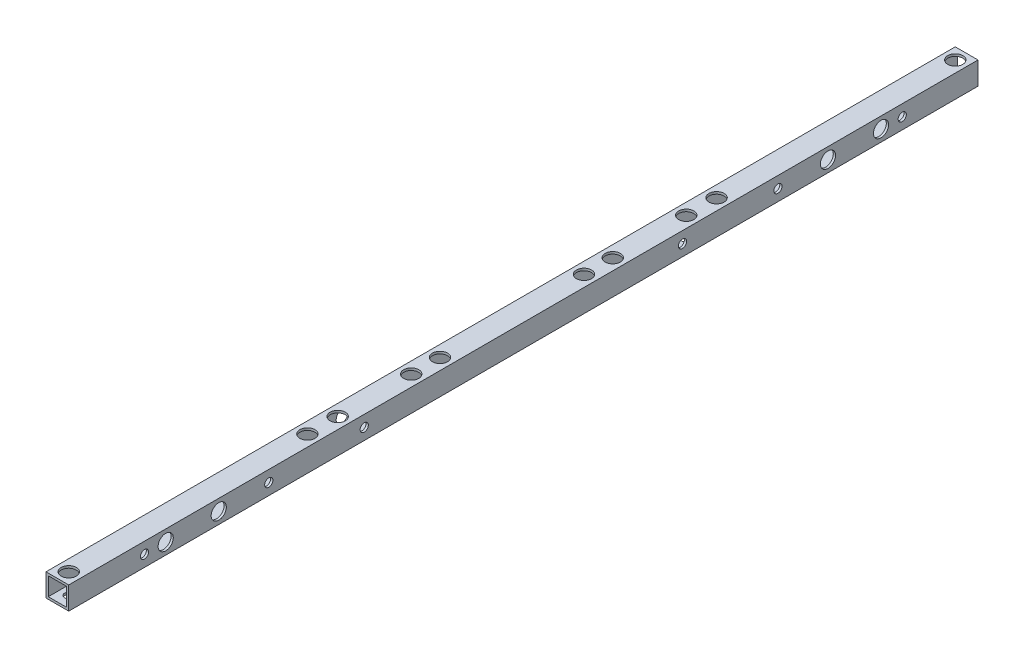
from build123d import *

# Parameters (mm, degrees)
SKETCH_1_W          = 15
SKETCH_1_H          = 15
SKETCH_1_W_2        = 12
SKETCH_1_H_2        = 12
EXTRUDE_1_DEPTH     = 600
SKETCH_3_R          = 2.7
CUT_EXTRUDE_2_DEPTH = 25
SKETCH_4_R          = 2.7
CUT_EXTRUDE_3_DEPTH = 20
SKETCH_6_R          = 2.7
CUT_EXTRUDE_5_DEPTH = 30
SKETCH_7_R          = 5
CUT_EXTRUDE_6_DEPTH = 10
SKETCH_8_R          = 5
CUT_EXTRUDE_7_DEPTH = 10
SKETCH_9_R          = 5
CUT_EXTRUDE_8_DEPTH = 10


with BuildPart() as part:
    # ｽｹｯﾁ1 → ﾎﾞｽ - 押し出し1 (new body)
    with BuildSketch(Plane.XY):
        Rectangle(SKETCH_1_W, SKETCH_1_H)
        Rectangle(SKETCH_1_W_2, SKETCH_1_H_2, mode=Mode.SUBTRACT)
    extrude(amount=EXTRUDE_1_DEPTH)

    # ｽｹｯﾁ3 → ｶｯﾄ - 押し出し2 (cut)
    with BuildSketch(Plane(origin=(0, 7.5, 0), x_dir=(1, 0, 0), z_dir=(0, 1, 0))):
        with Locations((0, -7.5)):
            Circle(SKETCH_3_R)
        with Locations((0, -592.5)):
            Circle(SKETCH_3_R)
        with Locations((0, -233.5)):
            Circle(SKETCH_3_R)
        with Locations((0, -366.5)):
            Circle(SKETCH_3_R)
    extrude(amount=-CUT_EXTRUDE_2_DEPTH, mode=Mode.SUBTRACT)

    # ｽｹｯﾁ4 → ｶｯﾄ - 押し出し3 (cut)
    with BuildSketch(Plane(origin=(7.5, 0, 0), x_dir=(0, 0, -1), z_dir=(1, 0, 0))):
        with Locations((-536, 0)):
            Circle(SKETCH_4_R)
        with Locations((-501, 0)):
            Circle(SKETCH_4_R)
        with Locations((-99, 0)):
            Circle(SKETCH_4_R)
        with Locations((-64, 0)):
            Circle(SKETCH_4_R)
        with Locations((-468, 0)):
            Circle(SKETCH_4_R)
        with Locations((-550, 0)):
            Circle(SKETCH_4_R)
        with Locations((-405, 0)):
            Circle(SKETCH_4_R)
        with Locations((-195, 0)):
            Circle(SKETCH_4_R)
        with Locations((-50, 0)):
            Circle(SKETCH_4_R)
        with Locations((-132, 0)):
            Circle(SKETCH_4_R)
    extrude(amount=-CUT_EXTRUDE_3_DEPTH, mode=Mode.SUBTRACT)

    # ｽｹｯﾁ6 → ｶｯﾄ - 押し出し5 (cut)
    with BuildSketch(Plane(origin=(0, 7.5, 0), x_dir=(1, 0, 0), z_dir=(0, 1, 0))):
        with Locations((0, -435)):
            Circle(SKETCH_6_R)
        with Locations((0, -415)):
            Circle(SKETCH_6_R)
        with Locations((0, -165)):
            Circle(SKETCH_6_R)
        with Locations((0, -185)):
            Circle(SKETCH_6_R)
        with Locations((0, -347.5)):
            Circle(SKETCH_6_R)
        with Locations((0, -252.5)):
            Circle(SKETCH_6_R)
    extrude(amount=-CUT_EXTRUDE_5_DEPTH, mode=Mode.SUBTRACT)

    # ｽｹｯﾁ7 → ｶｯﾄ - 押し出し6 (cut)
    with BuildSketch(Plane(origin=(0, 7.5, 0), x_dir=(1, 0, 0), z_dir=(0, 1, 0))):
        with Locations((0, -592.5)):
            Circle(SKETCH_7_R)
        with Locations((0, -7.5)):
            Circle(SKETCH_7_R)
        with Locations((0, -185)):
            Circle(SKETCH_7_R)
        with Locations((0, -165)):
            Circle(SKETCH_7_R)
        with Locations((0, -435)):
            Circle(SKETCH_7_R)
        with Locations((0, -415)):
            Circle(SKETCH_7_R)
        with Locations((0, -366.5)):
            Circle(SKETCH_7_R)
        with Locations((0, -233.5)):
            Circle(SKETCH_7_R)
        with Locations((0, -252.5)):
            Circle(SKETCH_7_R)
        with Locations((0, -347.5)):
            Circle(SKETCH_7_R)
    extrude(amount=-CUT_EXTRUDE_6_DEPTH, mode=Mode.SUBTRACT)

    # ｽｹｯﾁ8 → ｶｯﾄ - 押し出し7 (cut)
    with BuildSketch(Plane(origin=(7.5, 0, 0), x_dir=(0, 0, -1), z_dir=(1, 0, 0))):
        with Locations((-64, 0)):
            Circle(SKETCH_8_R)
        with Locations((-99, 0)):
            Circle(SKETCH_8_R)
        with Locations((-536, 0)):
            Circle(SKETCH_8_R)
        with Locations((-501, 0)):
            Circle(SKETCH_8_R)
    extrude(amount=-CUT_EXTRUDE_7_DEPTH, mode=Mode.SUBTRACT)

    # ｽｹｯﾁ9 → ｶｯﾄ - 押し出し8 (cut)
    with BuildSketch(Plane.ZY.offset(7.5)):
        with Locations((468, 0)):
            Circle(SKETCH_9_R)
        with Locations((405, 0)):
            Circle(SKETCH_9_R)
        with Locations((550, 0)):
            Circle(SKETCH_9_R)
        with Locations((195, 0)):
            Circle(SKETCH_9_R)
        with Locations((50, 0)):
            Circle(SKETCH_9_R)
        with Locations((132, 0)):
            Circle(SKETCH_9_R)
    extrude(amount=-CUT_EXTRUDE_8_DEPTH, mode=Mode.SUBTRACT)


solid = part.part
